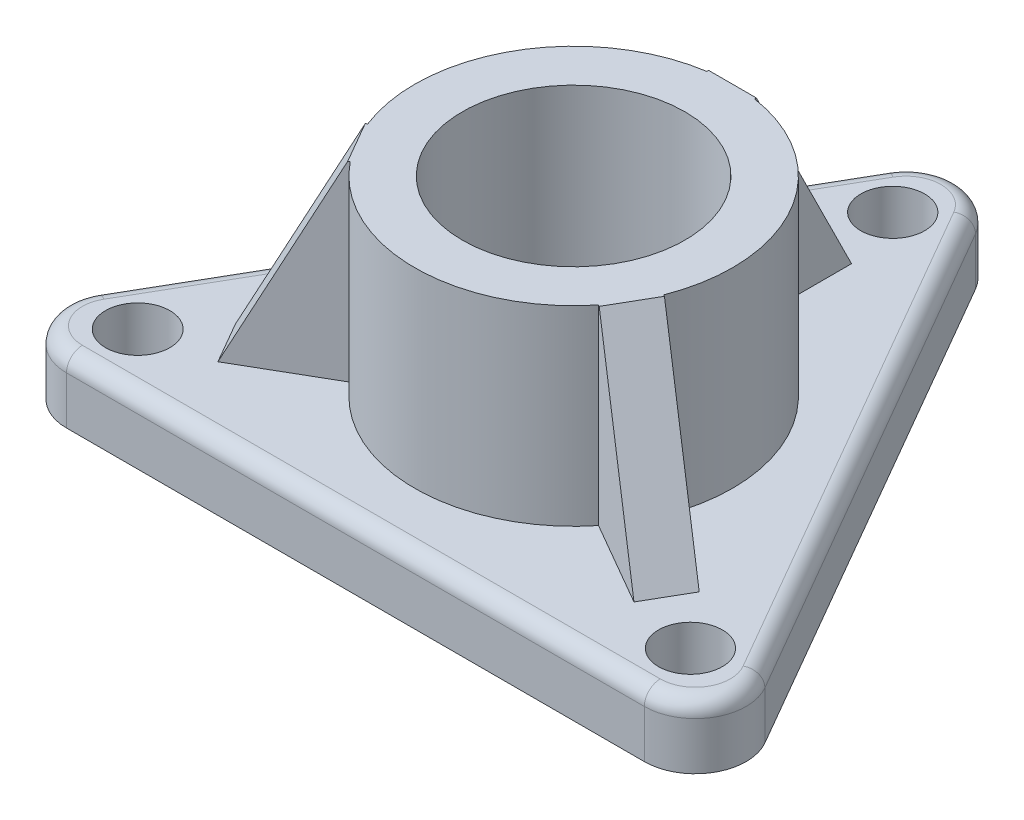
from build123d import *

# Parameters (mm, degrees)
SKETCH1_R           = 6.369474113
SKETCH1_R_2         = 6.364401416
SKETCH1_R_3         = 6.413225573
BOSS_EXTRUDE2_DEPTH = 12.7
FILLET5_R           = 9.906
FILLET6_R           = 10.16
FILLET7_R           = 10.16
FILLET8_R           = 3.175
SKETCH2_R           = 31.696441514
BOSS_EXTRUDE3_DEPTH = 38.1
SKETCH3_R           = 22.193645705
CUT_EXTRUDE1_DEPTH  = 31.75
BOSS_EXTRUDE4_DEPTH = 4.7625
BOSS_EXTRUDE6_DEPTH = 9.525
CIRPATTERN1_COUNT   = 3


with BuildPart() as part:
    # Sketch1 → Boss-Extrude2 (new body)
    with BuildSketch(Plane(origin=(0, 0, 0), x_dir=(1, 0, 0), z_dir=(0, 1, 0))):
        Polygon((0, 86.591919686), (-74.990802211, -43.295959843), (74.990802211, -43.295959843), align=None)
        with Locations((0, 63.638807052)):
            Circle(SKETCH1_R, mode=Mode.SUBTRACT)
        with Locations((55.112823574, -31.819403526)):
            Circle(SKETCH1_R_2, mode=Mode.SUBTRACT)
        with Locations((-55.112823574, -31.819403526)):
            Circle(SKETCH1_R_3, mode=Mode.SUBTRACT)
    extrude(amount=BOSS_EXTRUDE2_DEPTH)

    # Fillet5
    fillet5_edges = [part.edges().sort_by_distance(p)[0] for p in [
        (-74.990802211, 6.35, 43.295959843),
    ]]
    fillet(fillet5_edges, radius=FILLET5_R)

    # Fillet6
    fillet6_edges = [part.edges().sort_by_distance(p)[0] for p in [
        (74.990802211, 6.35, 43.295959843),
    ]]
    fillet(fillet6_edges, radius=FILLET6_R)

    # Fillet7
    fillet7_edges = [part.edges().sort_by_distance(p)[0] for p in [
        (0, 6.35, -86.591919686),
    ]]
    fillet(fillet7_edges, radius=FILLET7_R)

    # Fillet8
    fillet8_edges = [part.edges().sort_by_distance(p)[0] for p in [
        (-0.219970453, 12.7, 43.295959843),
        (-66.411954561, 12.7, 38.342959843),
        (37.495401105, 12.7, -21.647979922),
        (66.191984109, 12.7, 38.215959843),
        (-37.605386332, 12.7, -21.457479922),
        (0, 12.7, -76.431919686),
    ]]
    fillet(fillet8_edges, radius=FILLET8_R)

    # Sketch2 → Boss-Extrude3 (add)
    with BuildSketch(Plane(origin=(0, 12.7, 0), x_dir=(1, 0, 0), z_dir=(0, 1, 0))):
        Circle(SKETCH2_R)
    extrude(amount=BOSS_EXTRUDE3_DEPTH)

    # Sketch3 → Cut-Extrude1 (cut)
    with BuildSketch(Plane(origin=(0, 50.8, 0), x_dir=(1, 0, 0), z_dir=(0, 1, 0))):
        Circle(SKETCH3_R)
    extrude(amount=-CUT_EXTRUDE1_DEPTH, mode=Mode.SUBTRACT)

    # Sketch6 → Boss-Extrude4 (add)
    with BuildSketch(Plane(origin=(0, 0, 0), x_dir=(-0.866025404, 0, 0.5), z_dir=(-0.5, 0, -0.866025404))):
        Polygon((31.696441514, 12.7), (50.655531139, 12.7), (31.696441514, 50.8), (28.066895326, 50.8), (28.066895326, 12.7), align=None)
    extrude(amount=BOSS_EXTRUDE4_DEPTH)

    # Sketch8 → Boss-Extrude6 (add)
    with BuildSketch(Plane(origin=(-2.38125, 0, -4.124445986), x_dir=(-0.866025404, 0, 0.5), z_dir=(-0.5, 0, -0.866025404))):
        Polygon((31.005254456, 12.578941577), (50.655531139, 12.7), (31.696441514, 50.8), (27.148658098, 50.8), (27.148658098, 12.578941577), align=None)
    boss_extrude6 = extrude(amount=-BOSS_EXTRUDE6_DEPTH)

    # CirPattern1: Boss-Extrude6 ×3 about axis
    cirpattern1_axis = Axis((0, 0, 0), (0, 1, 0))
    for i in range(1, CIRPATTERN1_COUNT):
        add(boss_extrude6.rotate(cirpattern1_axis, i * 360 / CIRPATTERN1_COUNT))


solid = part.part
